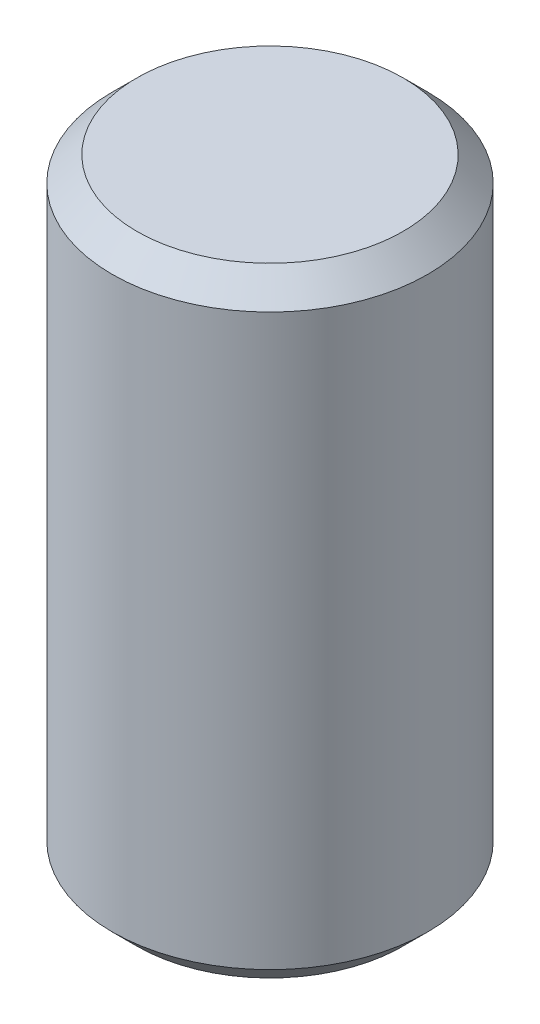
from build123d import *

# Parameters (mm, degrees)
SKETCH1_W     = 3.2385
SKETCH1_H     = 12.7
CHAMFER1_SIZE = 0.508


with BuildPart() as part:
    # Sketch1 → Revolve1 (revolve)
    with BuildSketch(Plane.XY):
        with Locations((1.61925, 0)):
            Rectangle(SKETCH1_W, SKETCH1_H)
    revolve(axis=Axis((0, 6.080207887, 0), (0, -1, 0)))

    # Chamfer1
    chamfer1_edges = [part.edges().sort_by_distance(p)[0] for p in [
        (-3.2385, 6.35, 0),
        (-3.2385, -6.35, 0),
    ]]
    chamfer(chamfer1_edges, length=CHAMFER1_SIZE)


solid = part.part
